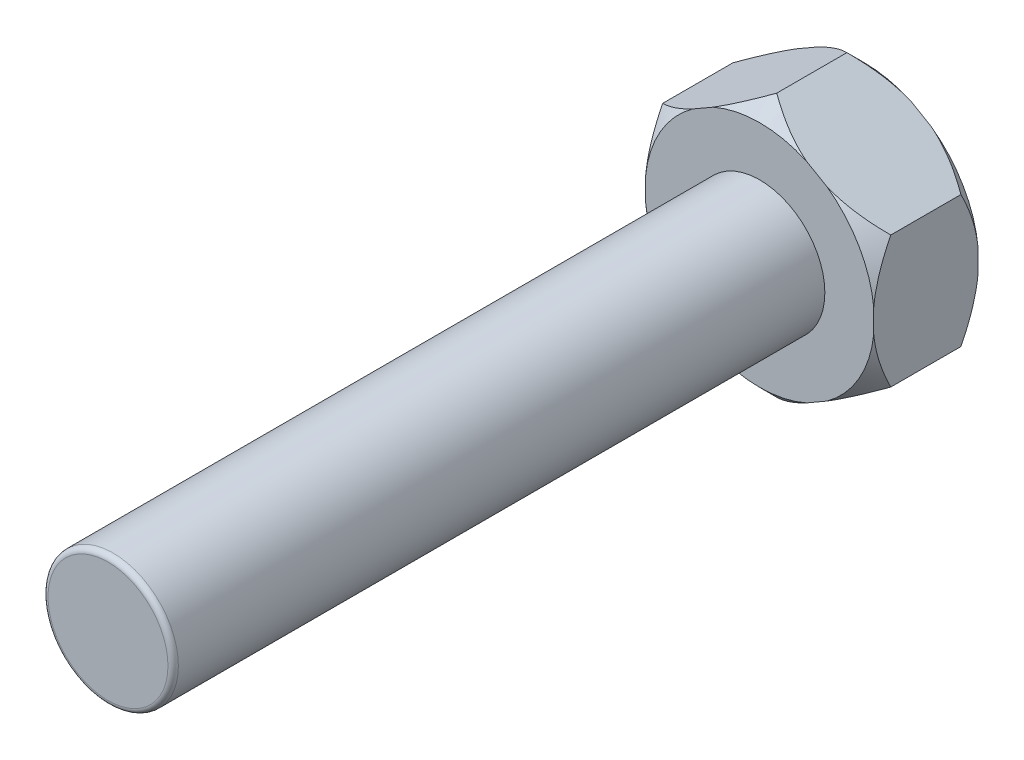
from build123d import *

# Parameters (mm, degrees)
EXTRUDE_1_DEPTH = 3.2
SKETCH_2_R      = 2
EXTRUDE_2_DEPTH = 20
FILLET_1_R      = 0.16


with BuildPart() as part:
    # 草图1 → 凸台-拉伸1 (new body)
    with BuildSketch(Plane.XY):
        Polygon((0, 4.041451884), (-3.5, 2.020725942), (-3.5, -2.020725942), (0, -4.041451884), (3.5, -2.020725942), (3.5, 2.020725942), align=None)
    extrude(amount=-EXTRUDE_1_DEPTH)

    # 草图2 → 凸台-拉伸2 (add)
    with BuildSketch(Plane.XY):
        Circle(SKETCH_2_R)
    extrude(amount=EXTRUDE_2_DEPTH)

    # 圆角1
    fillet_1_edges = [part.edges().sort_by_distance(p)[0] for p in [
        (-2, 0, 20),
    ]]
    fillet(fillet_1_edges, radius=FILLET_1_R)

    # 草图3 → 切除-旋转1 (revolve, cut)
    with BuildSketch(Plane(origin=(0, 0, 0), x_dir=(0, 0, -1), z_dir=(1, 0, 0))):
        Polygon((0.523, 4.041451884), (0, 3.518451884), (0, 4.041451884), align=None)
        Polygon((3.2, 4.041451884), (3.2, 3.518451884), (2.677, 4.041451884), align=None)
    revolve(axis=Axis((0, 0, 0), (0, 0, 1)), mode=Mode.SUBTRACT)


solid = part.part
